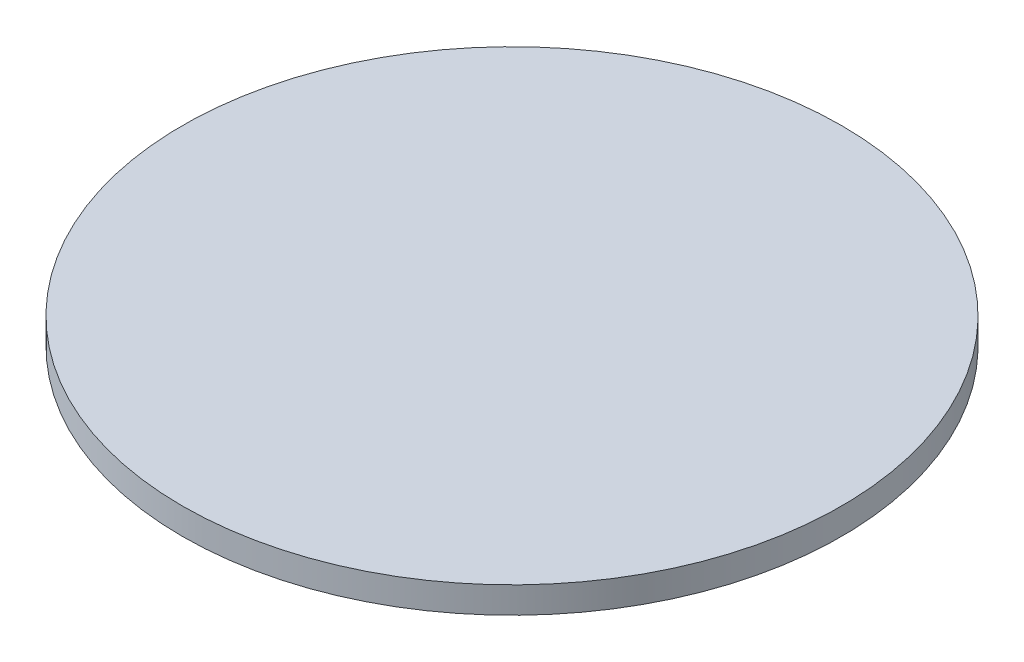
from build123d import *

# Parameters (mm, degrees)
SKETCH_1_R      = 100
EXTRUDE_1_DEPTH = 8


with BuildPart() as part:
    # 草图1 → 凸台-拉伸1 (new body)
    with BuildSketch(Plane(origin=(0, 0, 0), x_dir=(1, 0, 0), z_dir=(0, 1, 0))):
        Circle(SKETCH_1_R)
    extrude(amount=EXTRUDE_1_DEPTH)


solid = part.part
